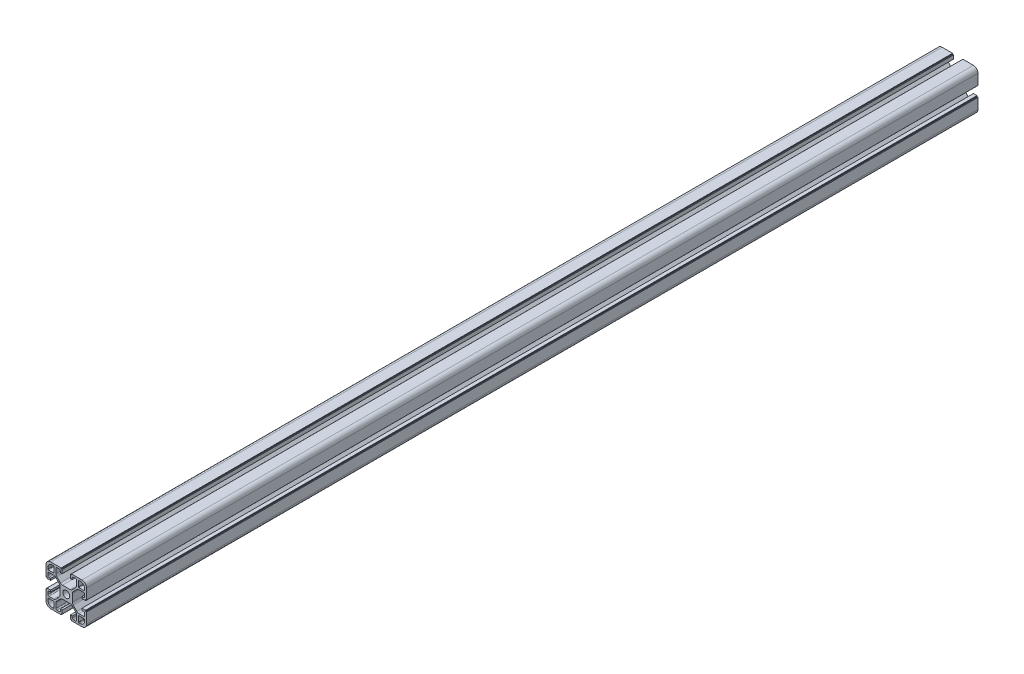
from build123d import *

# Parameters (mm, degrees)
BOSS_EXTRUDE1_DEPTH = 880


with BuildPart() as part:
    # Sketch2 → Boss-Extrude1 (new body)
    with BuildSketch(Plane.XY):
        with BuildLine():
            Line((84.170223908, 31.720417041), (84.170223908, 42.120417041))
            Line((84.170223908, 42.120417041), (83.570223908, 42.120417041))
            ThreePointArc((83.570223908, 42.120417041), (83.428802552, 42.178995685), (83.370223908, 42.320417041))
            Line((83.370223908, 42.320417041), (83.370223908, 42.920417041))
            ThreePointArc((83.370223908, 42.920417041), (83.311645264, 43.061838398), (83.170223908, 43.120417041))
            Line((83.170223908, 43.120417041), (79.670223908, 43.120417041))
            Line((79.670223908, 43.120417041), (79.670223908, 41.320417041))
            Line((79.670223908, 41.320417041), (81.370223908, 41.320417041))
            ThreePointArc((81.370223908, 41.320417041), (82.077330689, 41.027523823), (82.370223908, 40.320417041))
            Line((82.370223908, 40.320417041), (82.370223908, 37.970417041))
            ThreePointArc((82.370223908, 37.970417041), (82.077330689, 37.26331026), (81.370223908, 36.970417041))
            Line((81.370223908, 36.970417041), (76.723524767, 36.970417041))
            ThreePointArc((76.723524767, 36.970417041), (75.57547447, 37.198778444), (74.602204423, 37.849096698))
            Line((74.602204423, 37.849096698), (71.048903564, 41.402397557))
            ThreePointArc((71.048903564, 41.402397557), (70.39858531, 42.375667603), (70.170223908, 43.5237179))
            Line((70.170223908, 43.5237179), (70.170223908, 50.917116183))
            ThreePointArc((70.170223908, 50.917116183), (70.39858531, 52.06516648), (71.048903564, 53.038436526))
            Line((71.048903564, 53.038436526), (74.602204423, 56.591737385))
            ThreePointArc((74.602204423, 56.591737385), (75.57547447, 57.242055639), (76.723524767, 57.470417041))
            Line((76.723524767, 57.470417041), (81.370223908, 57.470417041))
            ThreePointArc((81.370223908, 57.470417041), (82.077330689, 57.177523823), (82.370223908, 56.470417041))
            Line((82.370223908, 56.470417041), (82.370223908, 54.120417041))
            ThreePointArc((82.370223908, 54.120417041), (82.077330689, 53.41331026), (81.370223908, 53.120417041))
            Line((81.370223908, 53.120417041), (79.670223908, 53.120417041))
            Line((79.670223908, 53.120417041), (79.670223908, 51.320417041))
            Line((79.670223908, 51.320417041), (83.170223908, 51.320417041))
            ThreePointArc((83.170223908, 51.320417041), (83.311645264, 51.378995685), (83.370223908, 51.520417041))
            Line((83.370223908, 51.520417041), (83.370223908, 52.120417041))
            ThreePointArc((83.370223908, 52.120417041), (83.428802552, 52.261838398), (83.570223908, 52.320417041))
            Line((83.570223908, 52.320417041), (84.170223908, 52.320417041))
            Line((84.170223908, 52.320417041), (84.170223908, 62.720417041))
            ThreePointArc((84.170223908, 62.720417041), (82.852204423, 65.902397557), (79.670223908, 67.220417041))
            Line((79.670223908, 67.220417041), (69.270223908, 67.220417041))
            Line((69.270223908, 67.220417041), (69.270223908, 66.420417041))
            Line((69.270223908, 66.420417041), (68.470223908, 66.420417041))
            ThreePointArc((68.470223908, 66.420417041), (68.328802552, 66.361838398), (68.270223908, 66.220417041))
            Line((68.270223908, 66.220417041), (68.270223908, 62.720417041))
            Line((68.270223908, 62.720417041), (70.070223908, 62.720417041))
            Line((70.070223908, 62.720417041), (70.070223908, 64.420417041))
            ThreePointArc((70.070223908, 64.420417041), (70.363117127, 65.127523823), (71.070223908, 65.420417041))
            Line((71.070223908, 65.420417041), (73.420223908, 65.420417041))
            ThreePointArc((73.420223908, 65.420417041), (74.127330689, 65.127523823), (74.420223908, 64.420417041))
            Line((74.420223908, 64.420417041), (74.420223908, 59.7737179))
            ThreePointArc((74.420223908, 59.7737179), (74.191862505, 58.625667603), (73.541544251, 57.652397557))
            Line((73.541544251, 57.652397557), (69.988243393, 54.099096698))
            ThreePointArc((69.988243393, 54.099096698), (69.014973346, 53.448778444), (67.866923049, 53.220417041))
            Line((67.866923049, 53.220417041), (60.473524767, 53.220417041))
            ThreePointArc((60.473524767, 53.220417041), (59.32547447, 53.448778444), (58.352204423, 54.099096698))
            Line((58.352204423, 54.099096698), (54.798903564, 57.652397557))
            ThreePointArc((54.798903564, 57.652397557), (54.14858531, 58.625667603), (53.920223908, 59.7737179))
            Line((53.920223908, 59.7737179), (53.920223908, 64.420417041))
            ThreePointArc((53.920223908, 64.420417041), (54.213117127, 65.127523823), (54.920223908, 65.420417041))
            Line((54.920223908, 65.420417041), (57.270223908, 65.420417041))
            ThreePointArc((57.270223908, 65.420417041), (57.977330689, 65.127523823), (58.270223908, 64.420417041))
            Line((58.270223908, 64.420417041), (58.270223908, 62.720417041))
            Line((58.270223908, 62.720417041), (60.070223908, 62.720417041))
            Line((60.070223908, 62.720417041), (60.070223908, 66.420417041))
            Line((60.070223908, 66.420417041), (59.270223908, 66.420417041))
            ThreePointArc((59.270223908, 66.420417041), (59.128802552, 66.478995685), (59.070223908, 66.620417041))
            Line((59.070223908, 66.620417041), (59.070223908, 67.220417041))
            Line((59.070223908, 67.220417041), (48.670223908, 67.220417041))
            ThreePointArc((48.670223908, 67.220417041), (45.488243393, 65.902397557), (44.170223908, 62.720417041))
            Line((44.170223908, 62.720417041), (44.170223908, 52.320417041))
            Line((44.170223908, 52.320417041), (44.770223908, 52.320417041))
            ThreePointArc((44.770223908, 52.320417041), (44.911645264, 52.261838398), (44.970223908, 52.120417041))
            Line((44.970223908, 52.120417041), (44.970223908, 51.520417041))
            ThreePointArc((44.970223908, 51.520417041), (45.028802552, 51.378995685), (45.170223908, 51.320417041))
            Line((45.170223908, 51.320417041), (48.670223908, 51.320417041))
            Line((48.670223908, 51.320417041), (48.670223908, 53.120417041))
            Line((48.670223908, 53.120417041), (46.970223908, 53.120417041))
            ThreePointArc((46.970223908, 53.120417041), (46.263117127, 53.41331026), (45.970223908, 54.120417041))
            Line((45.970223908, 54.120417041), (45.970223908, 56.470417041))
            ThreePointArc((45.970223908, 56.470417041), (46.263117127, 57.177523823), (46.970223908, 57.470417041))
            Line((46.970223908, 57.470417041), (51.616923049, 57.470417041))
            ThreePointArc((51.616923049, 57.470417041), (52.764973346, 57.242055639), (53.738243393, 56.591737385))
            Line((53.738243393, 56.591737385), (57.291544251, 53.038436526))
            ThreePointArc((57.291544251, 53.038436526), (57.941862505, 52.06516648), (58.170223908, 50.917116183))
            Line((58.170223908, 50.917116183), (58.170223908, 43.5237179))
            ThreePointArc((58.170223908, 43.5237179), (57.941862505, 42.375667603), (57.291544251, 41.402397557))
            Line((57.291544251, 41.402397557), (53.738243393, 37.849096698))
            ThreePointArc((53.738243393, 37.849096698), (52.764973346, 37.198778444), (51.616923049, 36.970417041))
            Line((51.616923049, 36.970417041), (46.970223908, 36.970417041))
            ThreePointArc((46.970223908, 36.970417041), (46.263117127, 37.26331026), (45.970223908, 37.970417041))
            Line((45.970223908, 37.970417041), (45.970223908, 40.320417041))
            ThreePointArc((45.970223908, 40.320417041), (46.263117127, 41.027523823), (46.970223908, 41.320417041))
            Line((46.970223908, 41.320417041), (48.670223908, 41.320417041))
            Line((48.670223908, 41.320417041), (48.670223908, 43.120417041))
            Line((48.670223908, 43.120417041), (45.170223908, 43.120417041))
            ThreePointArc((45.170223908, 43.120417041), (45.028802552, 43.061838398), (44.970223908, 42.920417041))
            Line((44.970223908, 42.920417041), (44.970223908, 42.320417041))
            ThreePointArc((44.970223908, 42.320417041), (44.911645264, 42.178995685), (44.770223908, 42.120417041))
            Line((44.770223908, 42.120417041), (44.170223908, 42.120417041))
            Line((44.170223908, 42.120417041), (44.170223908, 31.720417041))
            ThreePointArc((44.170223908, 31.720417041), (45.488243393, 28.538436526), (48.670223908, 27.220417041))
            Line((48.670223908, 27.220417041), (59.070223908, 27.220417041))
            Line((59.070223908, 27.220417041), (59.070223908, 27.820417041))
            ThreePointArc((59.070223908, 27.820417041), (59.128802552, 27.961838398), (59.270223908, 28.020417041))
            Line((59.270223908, 28.020417041), (59.870223908, 28.020417041))
            ThreePointArc((59.870223908, 28.020417041), (60.011645264, 28.078995685), (60.070223908, 28.220417041))
            Line((60.070223908, 28.220417041), (60.070223908, 31.720417041))
            Line((60.070223908, 31.720417041), (58.270223908, 31.720417041))
            Line((58.270223908, 31.720417041), (58.270223908, 30.020417041))
            ThreePointArc((58.270223908, 30.020417041), (57.977330689, 29.31331026), (57.270223908, 29.020417041))
            Line((57.270223908, 29.020417041), (54.920223908, 29.020417041))
            ThreePointArc((54.920223908, 29.020417041), (54.213117127, 29.31331026), (53.920223908, 30.020417041))
            Line((53.920223908, 30.020417041), (53.920223908, 34.667116183))
            ThreePointArc((53.920223908, 34.667116183), (54.14858531, 35.81516648), (54.798903564, 36.788436526))
            Line((54.798903564, 36.788436526), (58.352204423, 40.341737385))
            ThreePointArc((58.352204423, 40.341737385), (59.32547447, 40.992055639), (60.473524767, 41.220417041))
            Line((60.473524767, 41.220417041), (67.866923049, 41.220417041))
            ThreePointArc((67.866923049, 41.220417041), (69.014973346, 40.992055639), (69.988243393, 40.341737385))
            Line((69.988243393, 40.341737385), (73.541544251, 36.788436526))
            ThreePointArc((73.541544251, 36.788436526), (74.191862505, 35.81516648), (74.420223908, 34.667116183))
            Line((74.420223908, 34.667116183), (74.420223908, 30.020417041))
            ThreePointArc((74.420223908, 30.020417041), (74.127330689, 29.31331026), (73.420223908, 29.020417041))
            Line((73.420223908, 29.020417041), (71.070223908, 29.020417041))
            ThreePointArc((71.070223908, 29.020417041), (70.363117127, 29.31331026), (70.070223908, 30.020417041))
            Line((70.070223908, 30.020417041), (70.070223908, 31.720417041))
            Line((70.070223908, 31.720417041), (68.270223908, 31.720417041))
            Line((68.270223908, 31.720417041), (68.270223908, 28.220417041))
            ThreePointArc((68.270223908, 28.220417041), (68.328802552, 28.078995685), (68.470223908, 28.020417041))
            Line((68.470223908, 28.020417041), (69.070223908, 28.020417041))
            ThreePointArc((69.070223908, 28.020417041), (69.211645264, 27.961838398), (69.270223908, 27.820417041))
            Line((69.270223908, 27.820417041), (69.270223908, 27.220417041))
            Line((69.270223908, 27.220417041), (79.670223908, 27.220417041))
            ThreePointArc((79.670223908, 27.220417041), (82.852204423, 28.538436526), (84.170223908, 31.720417041))
        make_face()
        with BuildLine():
            Line((82.370223908, 34.670417041), (82.370223908, 33.520417041))
            ThreePointArc((82.370223908, 33.520417041), (81.052204423, 30.338436526), (77.870223908, 29.020417041))
            Line((77.870223908, 29.020417041), (76.720223908, 29.020417041))
            ThreePointArc((76.720223908, 29.020417041), (76.366670517, 29.166863651), (76.220223908, 29.520417041))
            Line((76.220223908, 29.520417041), (76.220223908, 34.670417041))
            ThreePointArc((76.220223908, 34.670417041), (76.366670517, 35.023970432), (76.720223908, 35.170417041))
            Line((76.720223908, 35.170417041), (81.870223908, 35.170417041))
            ThreePointArc((81.870223908, 35.170417041), (82.223777298, 35.023970432), (82.370223908, 34.670417041))
        make_face(mode=Mode.SUBTRACT)
        with BuildLine():
            Line((51.620223908, 29.020417041), (50.470223908, 29.020417041))
            ThreePointArc((50.470223908, 29.020417041), (47.288243393, 30.338436526), (45.970223908, 33.520417041))
            Line((45.970223908, 33.520417041), (45.970223908, 34.670417041))
            ThreePointArc((45.970223908, 34.670417041), (46.116670517, 35.023970432), (46.470223908, 35.170417041))
            Line((46.470223908, 35.170417041), (51.620223908, 35.170417041))
            ThreePointArc((51.620223908, 35.170417041), (51.973777298, 35.023970432), (52.120223908, 34.670417041))
            Line((52.120223908, 34.670417041), (52.120223908, 29.520417041))
            ThreePointArc((52.120223908, 29.520417041), (51.973777298, 29.166863651), (51.620223908, 29.020417041))
        make_face(mode=Mode.SUBTRACT)
        with BuildLine():
            Line((45.970223908, 59.770417041), (45.970223908, 60.920417041))
            ThreePointArc((45.970223908, 60.920417041), (47.288243393, 64.102397557), (50.470223908, 65.420417041))
            Line((50.470223908, 65.420417041), (51.620223908, 65.420417041))
            ThreePointArc((51.620223908, 65.420417041), (51.973777298, 65.273970432), (52.120223908, 64.920417041))
            Line((52.120223908, 64.920417041), (52.120223908, 59.770417041))
            ThreePointArc((52.120223908, 59.770417041), (51.973777298, 59.416863651), (51.620223908, 59.270417041))
            Line((51.620223908, 59.270417041), (46.470223908, 59.270417041))
            ThreePointArc((46.470223908, 59.270417041), (46.116670517, 59.416863651), (45.970223908, 59.770417041))
        make_face(mode=Mode.SUBTRACT)
        with BuildLine():
            Line((76.720223908, 65.420417041), (77.870223908, 65.420417041))
            ThreePointArc((77.870223908, 65.420417041), (81.052204423, 64.102397557), (82.370223908, 60.920417041))
            Line((82.370223908, 60.920417041), (82.370223908, 59.770417041))
            ThreePointArc((82.370223908, 59.770417041), (82.223777298, 59.416863651), (81.870223908, 59.270417041))
            Line((81.870223908, 59.270417041), (76.720223908, 59.270417041))
            ThreePointArc((76.720223908, 59.270417041), (76.366670517, 59.416863651), (76.220223908, 59.770417041))
            Line((76.220223908, 59.770417041), (76.220223908, 64.920417041))
            ThreePointArc((76.220223908, 64.920417041), (76.366670517, 65.273970432), (76.720223908, 65.420417041))
        make_face(mode=Mode.SUBTRACT)
        with BuildLine():
            ThreePointArc((60.770223908, 47.220417041), (64.170223908, 43.820417041), (67.570223908, 47.220417041))
            ThreePointArc((67.570223908, 47.220417041), (64.170223908, 50.620417041), (60.770223908, 47.220417041))
        make_face(mode=Mode.SUBTRACT)
    extrude(amount=BOSS_EXTRUDE1_DEPTH)


solid = part.part
